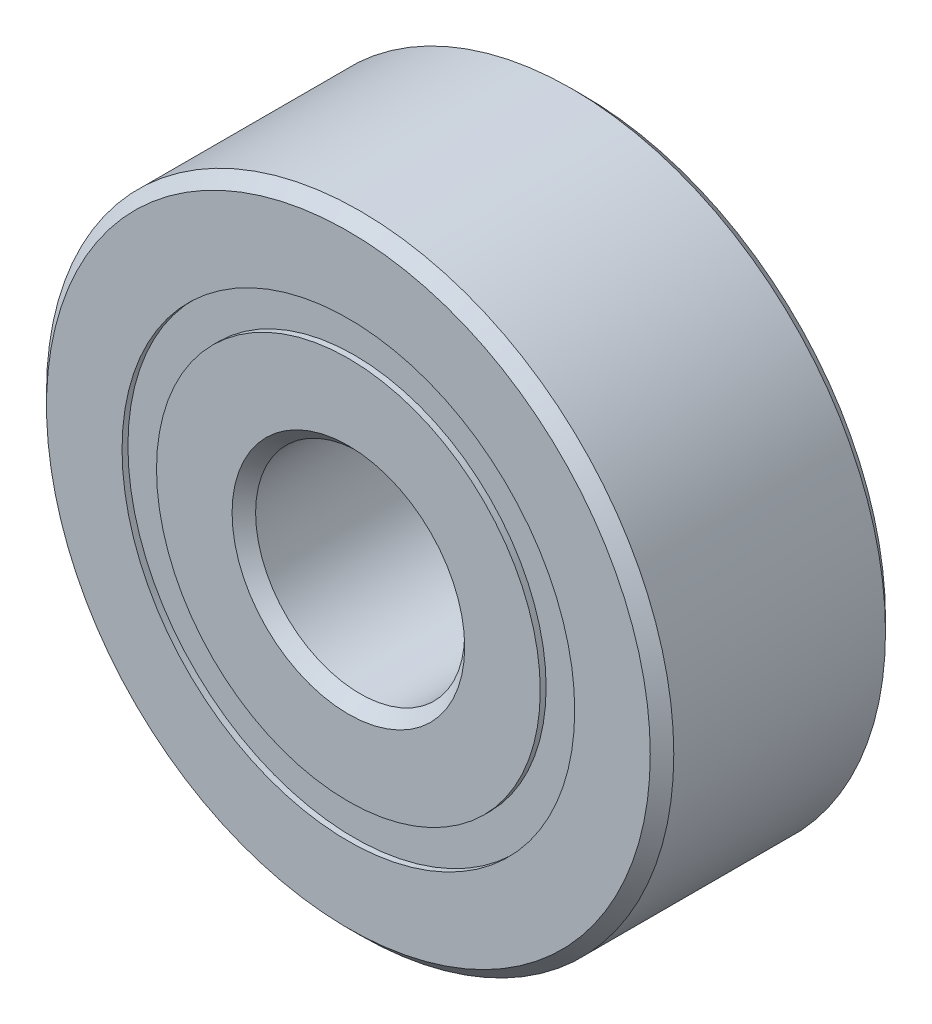
from build123d import *

# Parameters (mm, degrees)
CIRPATTERN1_COUNT = 10
SKETCH5_W         = 1.721739088
SKETCH5_H         = 1.046703296


with BuildPart() as part:
    # Sketch1 → Revolve1 (revolve)
    with BuildSketch(Plane(origin=(0, 0, 0), x_dir=(0, 0, -1), z_dir=(1, 0, 0))):
        with BuildLine():
            Line((3.2146875, 9.525), (-3.2146875, 9.525))
            Line((-3.2146875, 9.525), (-3.571875, 9.1678125))
            Line((-3.571875, 9.1678125), (-3.571875, 6.873351648))
            Line((-3.571875, 6.873351648), (-1.5875, 6.873351648))
            ThreePointArc((-1.5875, 6.873351648), (0, 8.021542162), (1.5875, 6.873351648))
            Line((1.5875, 6.873351648), (3.571875, 6.873351648))
            Line((3.571875, 6.873351648), (3.571875, 9.1678125))
            Line((3.571875, 9.1678125), (3.2146875, 9.525))
        make_face()
    revolve(axis=Axis((0, 0, 3.571875), (0, 0, -1)))


with BuildPart() as body_2:
    # Sketch3 → Revolve3 (revolve)
    with BuildSketch(Plane(origin=(0, 0, 0), x_dir=(0, 0, -1), z_dir=(1, 0, 0))):
        with BuildLine():
            Line((-3.571875, 5.826648352), (-1.5875, 5.826648352))
            ThreePointArc((-1.5875, 5.826648352), (0, 4.678457838), (1.5875, 5.826648352))
            Line((1.5875, 5.826648352), (3.571875, 5.826648352))
            Line((3.571875, 5.826648352), (3.571875, 3.5321875))
            Line((3.571875, 3.5321875), (3.2146875, 3.175))
            Line((3.2146875, 3.175), (-3.2146875, 3.175))
            Line((-3.2146875, 3.175), (-3.571875, 3.5321875))
            Line((-3.571875, 3.5321875), (-3.571875, 5.826648352))
        make_face()
    revolve(axis=Axis((0, 0, 3.571875), (0, 0, -1)))


with BuildPart() as body_3:
    # Sketch4 → Revolve4 (revolve)
    with BuildSketch(Plane(origin=(0, 0, 0), x_dir=(0, 0, -1), z_dir=(1, 0, 0))):
        with BuildLine():
            Line((-1.671542162, 6.35), (1.671542162, 6.35))
            ThreePointArc((1.671542162, 6.35), (0, 8.021542162), (-1.671542162, 6.35))
        make_face()
    revolve(axis=Axis((0, 6.35, 1.671542162), (0, 0, -1)))


with BuildPart() as cirpattern1_1:
    # CirPattern1: pattern copy
    add(body_3.part.rotate(Axis((0, 0, -3.571875), (0, 0, 1)), 1 * 360 / CIRPATTERN1_COUNT))


with BuildPart() as cirpattern1_2:
    # CirPattern1: pattern copy
    add(body_3.part.rotate(Axis((0, 0, -3.571875), (0, 0, 1)), 2 * 360 / CIRPATTERN1_COUNT))


with BuildPart() as cirpattern1_3:
    # CirPattern1: pattern copy
    add(body_3.part.rotate(Axis((0, 0, -3.571875), (0, 0, 1)), 3 * 360 / CIRPATTERN1_COUNT))


with BuildPart() as cirpattern1_4:
    # CirPattern1: pattern copy
    add(body_3.part.rotate(Axis((0, 0, -3.571875), (0, 0, 1)), 4 * 360 / CIRPATTERN1_COUNT))


with BuildPart() as cirpattern1_5:
    # CirPattern1: pattern copy
    add(body_3.part.rotate(Axis((0, 0, -3.571875), (0, 0, 1)), 5 * 360 / CIRPATTERN1_COUNT))


with BuildPart() as cirpattern1_6:
    # CirPattern1: pattern copy
    add(body_3.part.rotate(Axis((0, 0, -3.571875), (0, 0, 1)), 6 * 360 / CIRPATTERN1_COUNT))


with BuildPart() as cirpattern1_7:
    # CirPattern1: pattern copy
    add(body_3.part.rotate(Axis((0, 0, -3.571875), (0, 0, 1)), 7 * 360 / CIRPATTERN1_COUNT))


with BuildPart() as cirpattern1_8:
    # CirPattern1: pattern copy
    add(body_3.part.rotate(Axis((0, 0, -3.571875), (0, 0, 1)), 8 * 360 / CIRPATTERN1_COUNT))


with BuildPart() as cirpattern1_9:
    # CirPattern1: pattern copy
    add(body_3.part.rotate(Axis((0, 0, -3.571875), (0, 0, 1)), 9 * 360 / CIRPATTERN1_COUNT))


with BuildPart() as body_13:
    # Sketch5 → Revolve5 (revolve)
    with BuildSketch(Plane(origin=(0, 0, 0), x_dir=(0, 0, -1), z_dir=(1, 0, 0))):
        with Locations((-2.532411706, 6.35)):
            Rectangle(SKETCH5_W, SKETCH5_H)
        with Locations((2.532411706, 6.35)):
            Rectangle(SKETCH5_W, SKETCH5_H)
    revolve(axis=Axis((0, 0, 3.571875), (0, 0, -1)))


solid = Compound([part.part, body_2.part, body_3.part, cirpattern1_1.part, cirpattern1_2.part, cirpattern1_3.part, cirpattern1_4.part, cirpattern1_5.part, cirpattern1_6.part, cirpattern1_7.part, cirpattern1_8.part, cirpattern1_9.part, body_13.part])
